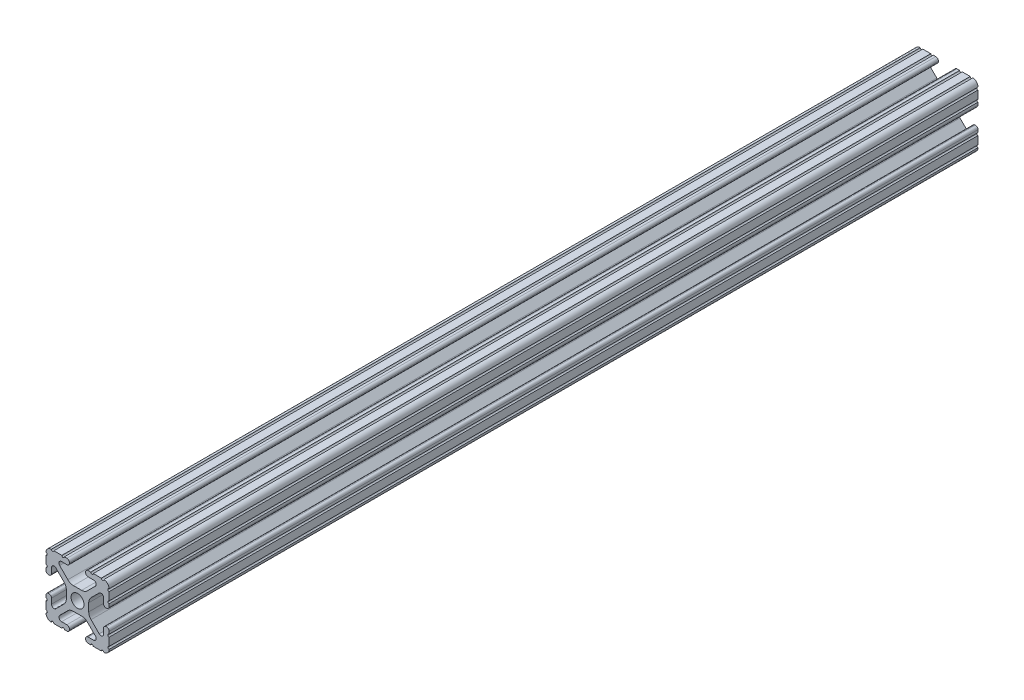
from build123d import *

# Parameters (mm, degrees)
SKETCH1_R           = 2.6035
BOSS_EXTRUDE1_DEPTH = 350


with BuildPart() as part:
    # Sketch1 → Boss-Extrude1 (new body)
    with BuildSketch(Plane.XY):
        with BuildLine():
            Line((-7.179650497, -8.645192506), (-3.952270251, -5.423690499))
            ThreePointArc((-3.952270251, -5.423690499), (-2.922936451, -4.736929036), (-1.709253557, -4.4958))
            Line((-1.709253557, -4.4958), (1.709253557, -4.4958))
            ThreePointArc((1.709253557, -4.4958), (2.922936451, -4.736929036), (3.952270251, -5.423690499))
            Line((3.952270251, -5.423690499), (7.179650497, -8.645192506))
            ThreePointArc((7.179650497, -8.645192506), (7.41473083, -9.822813117), (6.416408329, -10.4902))
            Line((6.416408329, -10.4902), (4.287512407, -10.4902))
            ThreePointArc((4.287512407, -10.4902), (3.54574862, -10.79744862), (3.2385, -11.539212407))
            Line((3.2385, -11.539212407), (3.2385, -11.650987593))
            ThreePointArc((3.2385, -11.650987593), (3.54574862, -12.39275138), (4.287512407, -12.7))
            Line((4.287512407, -12.7), (5.317126718, -12.7))
            ThreePointArc((5.317126718, -12.7), (5.825126718, -12.192), (6.333126718, -12.7))
            Line((6.333126718, -12.7), (9.550443118, -12.7))
            ThreePointArc((9.550443118, -12.7), (10.058366869, -12.192000006), (10.566443095, -12.699847501))
            ThreePointArc((10.566443095, -12.699847501), (12.082537762, -12.08250727), (12.699846982, -10.566399977))
            ThreePointArc((12.699846982, -10.566399977), (12.192000006, -10.058323491), (12.7, -9.5504))
            Line((12.7, -9.5504), (12.7, -6.3330836))
            ThreePointArc((12.7, -6.3330836), (12.192, -5.8250836), (12.7, -5.3170836))
            Line((12.7, -5.3170836), (12.7, -4.287469289))
            ThreePointArc((12.7, -4.287469289), (12.39275138, -3.545705502), (11.650987593, -3.238456882))
            Line((11.650987593, -3.238456882), (11.539212407, -3.238456882))
            ThreePointArc((11.539212407, -3.238456882), (10.79744862, -3.545705502), (10.4902, -4.287469289))
            Line((10.4902, -4.287469289), (10.4902, -6.402089023))
            ThreePointArc((10.4902, -6.402089023), (9.856505071, -7.351067942), (8.737131347, -7.129408934))
            Line((8.737131347, -7.129408934), (5.441005833, -3.840816462))
            ThreePointArc((5.441005833, -3.840816462), (4.750877967, -2.809883091), (4.5085, -1.593185507))
            Line((4.5085, -1.593185507), (4.5085, 1.593185507))
            ThreePointArc((4.5085, 1.593185507), (4.750877967, 2.809883091), (5.441005833, 3.840816462))
            Line((5.441005833, 3.840816462), (8.737131347, 7.129408934))
            ThreePointArc((8.737131347, 7.129408934), (9.856505071, 7.351067942), (10.4902, 6.402089023))
            Line((10.4902, 6.402089023), (10.4902, 4.287469289))
            ThreePointArc((10.4902, 4.287469289), (10.79744862, 3.545705502), (11.539212407, 3.238456882))
            Line((11.539212407, 3.238456882), (11.650987593, 3.238456882))
            ThreePointArc((11.650987593, 3.238456882), (12.39275138, 3.545705502), (12.7, 4.287469289))
            Line((12.7, 4.287469289), (12.7, 5.3170836))
            ThreePointArc((12.7, 5.3170836), (12.192, 5.8250836), (12.7, 6.3330836))
            Line((12.7, 6.3330836), (12.7, 9.5504))
            ThreePointArc((12.7, 9.5504), (12.192000006, 10.058323491), (12.699846982, 10.566399977))
            ThreePointArc((12.699846982, 10.566399977), (12.082537762, 12.08250727), (10.566443095, 12.699847501))
            ThreePointArc((10.566443095, 12.699847501), (10.058366869, 12.192000006), (9.550443118, 12.7))
            Line((9.550443118, 12.7), (6.333126718, 12.7))
            ThreePointArc((6.333126718, 12.7), (5.825126718, 12.192), (5.317126718, 12.7))
            Line((5.317126718, 12.7), (4.287512407, 12.7))
            ThreePointArc((4.287512407, 12.7), (3.54574862, 12.39275138), (3.2385, 11.650987593))
            Line((3.2385, 11.650987593), (3.2385, 11.539212407))
            ThreePointArc((3.2385, 11.539212407), (3.54574862, 10.79744862), (4.287512407, 10.4902))
            Line((4.287512407, 10.4902), (6.476788598, 10.4902))
            ThreePointArc((6.476788598, 10.4902), (7.432222385, 9.85140422), (7.207036008, 8.724370562))
            Line((7.207036008, 8.724370562), (3.898272566, 5.423169045))
            ThreePointArc((3.898272566, 5.423169045), (2.869120213, 4.736787962), (1.655778399, 4.4958))
            Line((1.655778399, 4.4958), (-1.655778399, 4.4958))
            ThreePointArc((-1.655778399, 4.4958), (-2.869120213, 4.736787962), (-3.898272566, 5.423169045))
            Line((-3.898272566, 5.423169045), (-7.207036008, 8.724370562))
            ThreePointArc((-7.207036008, 8.724370562), (-7.432222385, 9.85140422), (-6.476788598, 10.4902))
            Line((-6.476788598, 10.4902), (-4.287512407, 10.4902))
            ThreePointArc((-4.287512407, 10.4902), (-3.54574862, 10.79744862), (-3.2385, 11.539212407))
            Line((-3.2385, 11.539212407), (-3.2385, 11.650987593))
            ThreePointArc((-3.2385, 11.650987593), (-3.54574862, 12.39275138), (-4.287512407, 12.7))
            Line((-4.287512407, 12.7), (-5.317126718, 12.7))
            ThreePointArc((-5.317126718, 12.7), (-5.825126718, 12.192), (-6.333126718, 12.7))
            Line((-6.333126718, 12.7), (-9.550443118, 12.7))
            ThreePointArc((-9.550443118, 12.7), (-10.058366869, 12.192000006), (-10.566443095, 12.699847501))
            ThreePointArc((-10.566443095, 12.699847501), (-12.082537762, 12.08250727), (-12.699846982, 10.566399977))
            ThreePointArc((-12.699846982, 10.566399977), (-12.192000006, 10.058323491), (-12.7, 9.5504))
            Line((-12.7, 9.5504), (-12.7, 6.3330836))
            ThreePointArc((-12.7, 6.3330836), (-12.192, 5.8250836), (-12.7, 5.3170836))
            Line((-12.7, 5.3170836), (-12.7, 4.287469289))
            ThreePointArc((-12.7, 4.287469289), (-12.39275138, 3.545705502), (-11.650987593, 3.238456882))
            Line((-11.650987593, 3.238456882), (-11.539212407, 3.238456882))
            ThreePointArc((-11.539212407, 3.238456882), (-10.79744862, 3.545705502), (-10.4902, 4.287469289))
            Line((-10.4902, 4.287469289), (-10.4902, 6.402089023))
            ThreePointArc((-10.4902, 6.402089023), (-9.856505071, 7.351067942), (-8.737131347, 7.129408934))
            Line((-8.737131347, 7.129408934), (-5.441005833, 3.840816462))
            ThreePointArc((-5.441005833, 3.840816462), (-4.750877967, 2.809883091), (-4.5085, 1.593185507))
            Line((-4.5085, 1.593185507), (-4.5085, -1.593185507))
            ThreePointArc((-4.5085, -1.593185507), (-4.750877967, -2.809883091), (-5.441005833, -3.840816462))
            Line((-5.441005833, -3.840816462), (-8.737131347, -7.129408934))
            ThreePointArc((-8.737131347, -7.129408934), (-9.856505071, -7.351067942), (-10.4902, -6.402089023))
            Line((-10.4902, -6.402089023), (-10.4902, -4.287469289))
            ThreePointArc((-10.4902, -4.287469289), (-10.79744862, -3.545705502), (-11.539212407, -3.238456882))
            Line((-11.539212407, -3.238456882), (-11.650987593, -3.238456882))
            ThreePointArc((-11.650987593, -3.238456882), (-12.39275138, -3.545705502), (-12.7, -4.287469289))
            Line((-12.7, -4.287469289), (-12.7, -5.3170836))
            ThreePointArc((-12.7, -5.3170836), (-12.192, -5.8250836), (-12.7, -6.3330836))
            Line((-12.7, -6.3330836), (-12.7, -9.5504))
            ThreePointArc((-12.7, -9.5504), (-12.192000006, -10.058323491), (-12.699846982, -10.566399977))
            ThreePointArc((-12.699846982, -10.566399977), (-12.082537762, -12.08250727), (-10.566443095, -12.699847501))
            ThreePointArc((-10.566443095, -12.699847501), (-10.058366869, -12.192000006), (-9.550443118, -12.7))
            Line((-9.550443118, -12.7), (-6.333126718, -12.7))
            ThreePointArc((-6.333126718, -12.7), (-5.825126718, -12.192), (-5.317126718, -12.7))
            Line((-5.317126718, -12.7), (-4.287512407, -12.7))
            ThreePointArc((-4.287512407, -12.7), (-3.54574862, -12.39275138), (-3.2385, -11.650987593))
            Line((-3.2385, -11.650987593), (-3.2385, -11.539212407))
            ThreePointArc((-3.2385, -11.539212407), (-3.54574862, -10.79744862), (-4.287512407, -10.4902))
            Line((-4.287512407, -10.4902), (-6.416408329, -10.4902))
            ThreePointArc((-6.416408329, -10.4902), (-7.41473083, -9.822813117), (-7.179650497, -8.645192506))
        make_face()
        Circle(SKETCH1_R, mode=Mode.SUBTRACT)
    extrude(amount=BOSS_EXTRUDE1_DEPTH)


solid = part.part
